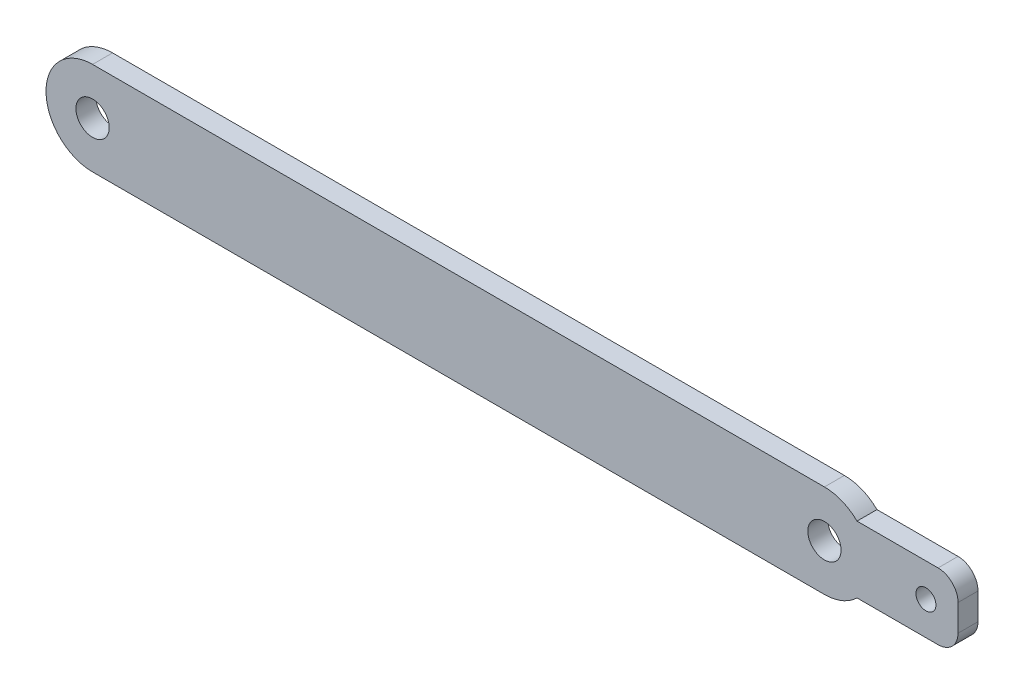
from build123d import *

# Parameters (mm, degrees)
SKETCH1_R           = 2.5
BOSS_EXTRUDE1_DEPTH = 3
SKETCH2_R           = 1.5
BOSS_EXTRUDE2_DEPTH = 3


with BuildPart() as part:
    # Sketch1 → Boss-Extrude1 (new body)
    with BuildSketch(Plane.XY):
        with BuildLine():
            Line((-70.959009299, 269.154117688), (39.040990701, 269.154117688))
            ThreePointArc((39.040990701, 269.154117688), (46.040990701, 262.154117688), (39.040990701, 255.154117688))
            Line((39.040990701, 255.154117688), (-70.959009299, 255.154117688))
            ThreePointArc((-70.959009299, 255.154117688), (-77.959009299, 262.154117688), (-70.959009299, 269.154117688))
        make_face()
        with Locations((-70.959009299, 262.154117688)):
            Circle(SKETCH1_R, mode=Mode.SUBTRACT)
        with Locations((39.040990701, 262.154117688)):
            Circle(SKETCH1_R, mode=Mode.SUBTRACT)
    extrude(amount=BOSS_EXTRUDE1_DEPTH)

    # Sketch2 → Boss-Extrude2 (add)
    with BuildSketch(Plane.XY.offset(3)):
        with BuildLine():
            Line((56.125358764, 267.154117688), (42.581100141, 267.154117688))
            Line((42.581100141, 267.154117688), (42.581100141, 257.154117688))
            Line((42.581100141, 257.154117688), (56.125358764, 257.154117688))
            ThreePointArc((56.125358764, 257.154117688), (58.246679107, 258.032797345), (59.125358764, 260.154117688))
            Line((59.125358764, 260.154117688), (59.125358764, 264.154117688))
            ThreePointArc((59.125358764, 264.154117688), (58.246679107, 266.275438032), (56.125358764, 267.154117688))
        make_face()
        with Locations((54.303681244, 262.154117688)):
            Circle(SKETCH2_R, mode=Mode.SUBTRACT)
    extrude(amount=-BOSS_EXTRUDE2_DEPTH)


solid = part.part
